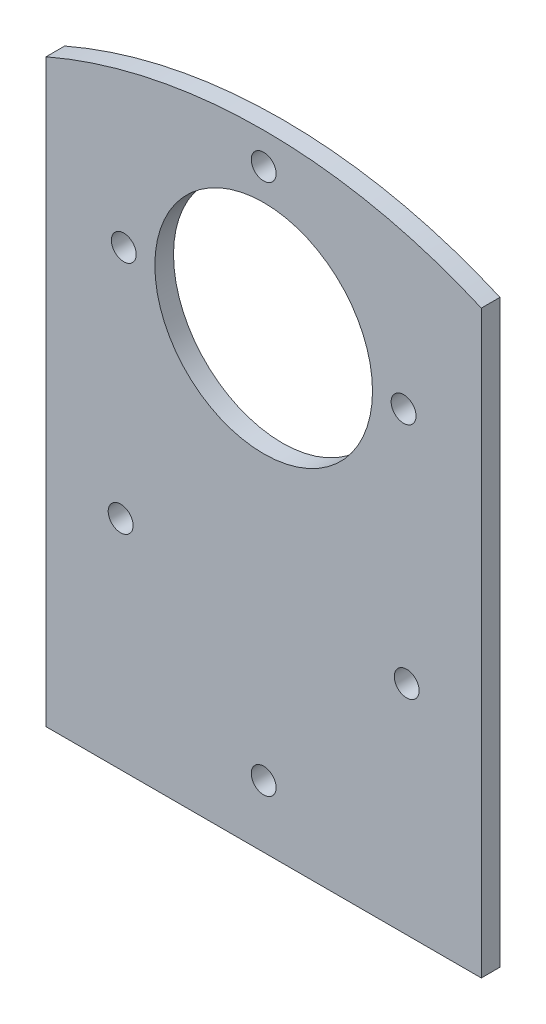
from build123d import *

# Parameters (mm, degrees)
SKETCH1_W           = 70
SKETCH1_H           = 105
BOSS_EXTRUDE1_DEPTH = 3
SKETCH2_R           = 17.5
CUT_EXTRUDE3_DEPTH  = 3
SKETCH3_R           = 2
CUT_EXTRUDE4_DEPTH  = 3
SKETCH4_R           = 2
CUT_EXTRUDE5_DEPTH  = 5
CUT_EXTRUDE6_DEPTH  = 10


with BuildPart() as part:
    # Sketch1 → Boss-Extrude1 (new body)
    with BuildSketch(Plane.XY):
        Rectangle(SKETCH1_W, SKETCH1_H)
    extrude(amount=BOSS_EXTRUDE1_DEPTH)

    # Sketch2 → Cut-Extrude3 (cut)
    with BuildSketch(Plane(origin=(0, 0, 0), x_dir=(-1, 0, 0), z_dir=(0, 0, -1))):
        with Locations((0, 20.5)):
            Circle(SKETCH2_R)
    extrude(amount=-CUT_EXTRUDE3_DEPTH, mode=Mode.SUBTRACT)

    # Sketch3 → Cut-Extrude4 (cut)
    with BuildSketch(Plane.XY.offset(3)):
        with Locations((-22.5, 20.5)):
            Circle(SKETCH3_R)
        with Locations((0, 43)):
            Circle(SKETCH3_R)
        with Locations((22.5, 20.5)):
            Circle(SKETCH3_R)
    extrude(amount=-CUT_EXTRUDE4_DEPTH, mode=Mode.SUBTRACT)

    # Sketch4 → Cut-Extrude5 (cut)
    with BuildSketch(Plane.XY.offset(3)):
        with Locations((0, -42.5)):
            Circle(SKETCH4_R)
        with Locations((-23, -17.5)):
            Circle(SKETCH4_R)
        with Locations((23, -17.5)):
            Circle(SKETCH4_R)
    extrude(amount=-CUT_EXTRUDE5_DEPTH, mode=Mode.SUBTRACT)

    # Sketch5 → Cut-Extrude6 (cut)
    with BuildSketch(Plane.XY.offset(3)):
        with BuildLine():
            Line((-35, 40.793543502), (-35, 52.5))
            Line((-35, 52.5), (35, 52.5))
            Line((35, 52.5), (35, 40.793543502))
            ThreePointArc((35, 40.793543502), (0, 48.07644174), (-35, 40.793543502))
        make_face()
    extrude(amount=-CUT_EXTRUDE6_DEPTH, mode=Mode.SUBTRACT)


solid = part.part
